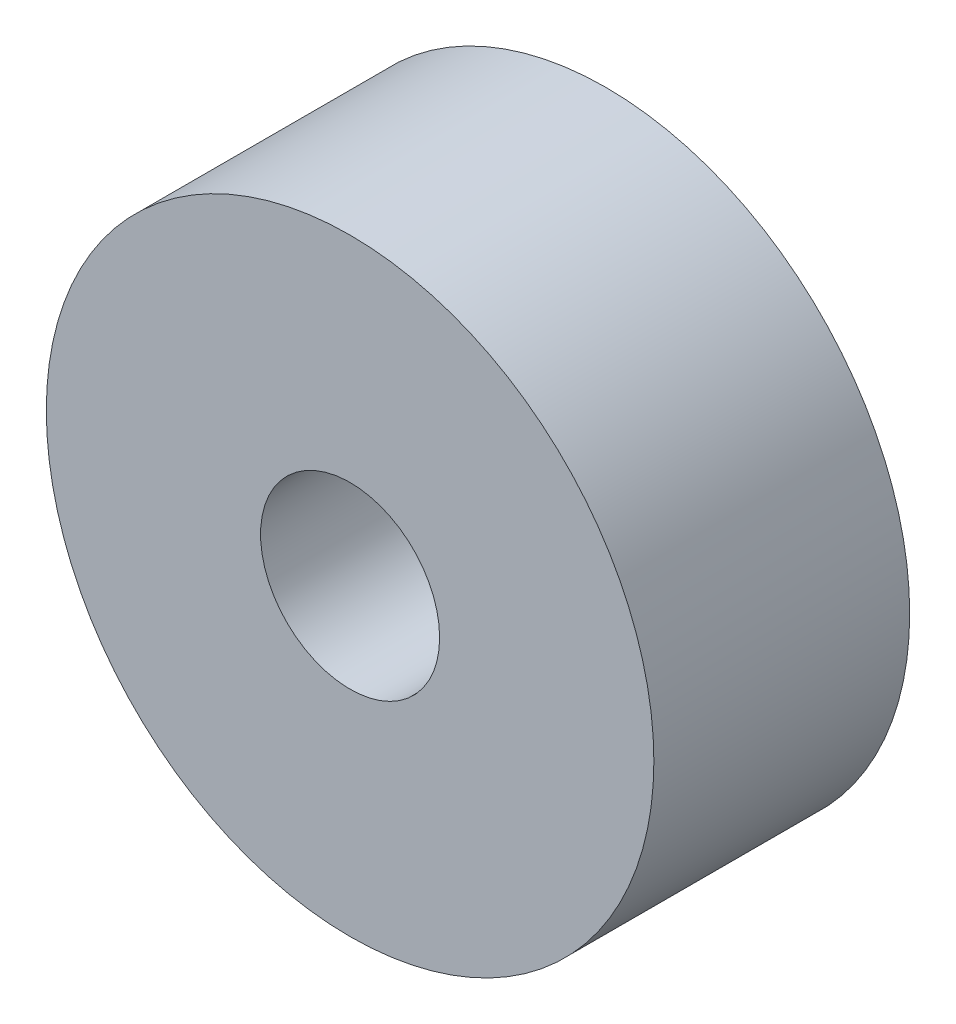
from build123d import *

# Parameters (mm, degrees)
SKETCH1_R          = 9.5
MAIN_EXTRUDE_DEPTH = 8
SKETCH2_R          = 2.8
CUT_EXTRUDE1_DEPTH = 10


with BuildPart() as part:
    # Sketch1 → Main Extrude (new body)
    with BuildSketch(Plane.XY):
        Circle(SKETCH1_R)
    extrude(amount=MAIN_EXTRUDE_DEPTH)

    # Sketch2 → Cut-Extrude1 (cut)
    with BuildSketch(Plane.XY.offset(8)):
        Circle(SKETCH2_R)
    extrude(amount=-CUT_EXTRUDE1_DEPTH, mode=Mode.SUBTRACT)


solid = part.part
